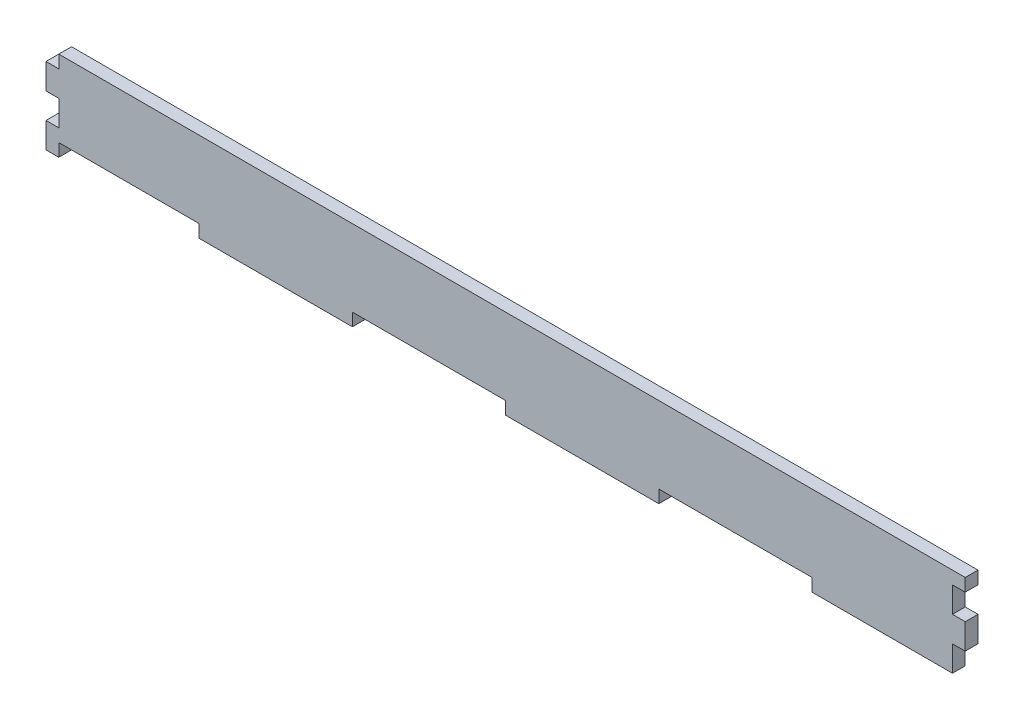
from build123d import *

# Parameters (mm, degrees)
BOSS_EXTRUDE1_DEPTH = 3.175


with BuildPart() as part:
    # Sketch1 → Boss-Extrude1 (new body)
    with BuildSketch(Plane.XY):
        Polygon((-111.125, 9.525), (-111.125, 6.35), (-114.3, 6.35), (-114.3, 0), (-111.125, 0), (-111.125, -6.35), (-114.3, -6.35), (-114.3, -12.7), (-111.125, -12.7), (-111.125, -9.525), (-76.2, -9.525), (-76.2, -12.7), (-38.1, -12.7), (-38.1, -9.525), (0, -9.525), (0, -12.7), (38.1, -12.7), (38.1, -9.525), (76.2, -9.525), (76.2, -12.7), (111.125, -12.7), (111.125, -6.35), (114.3, -6.35), (114.3, 0), (111.125, 0), (111.125, 6.35), (114.3, 6.35), (114.3, 9.525), align=None)
    extrude(amount=BOSS_EXTRUDE1_DEPTH)


solid = part.part
